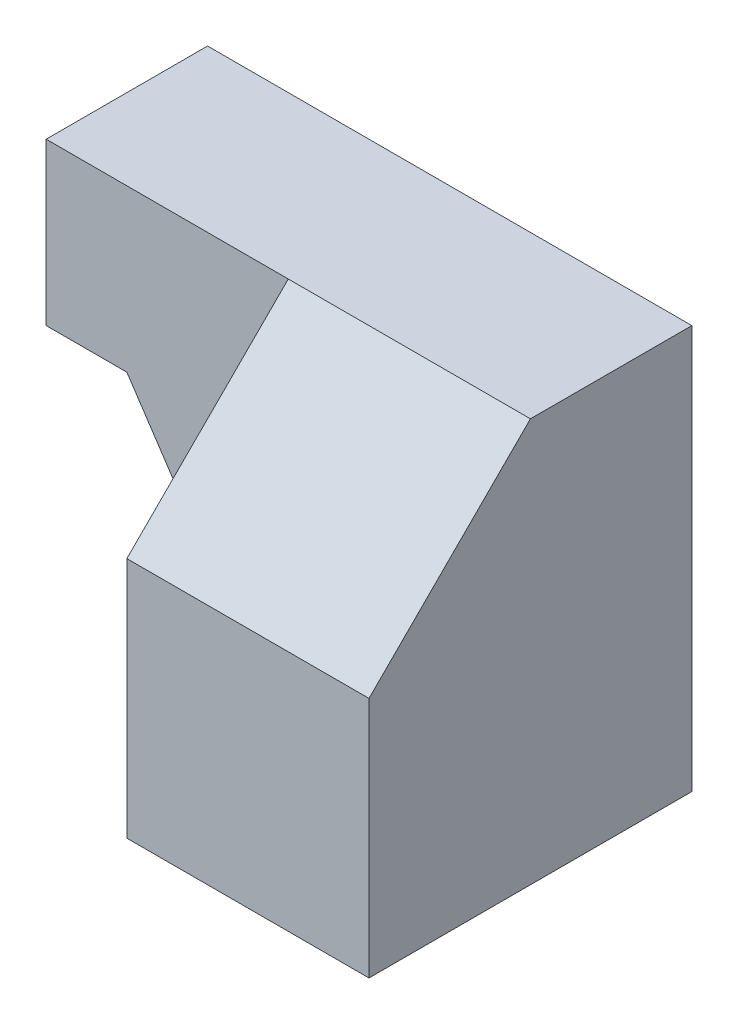
from build123d import *

# Parameters (mm, degrees)
BOSS_EXTRUDE1_DEPTH = 20
CUT_EXTRUDE1_DEPTH  = 10
CUT_EXTRUDE3_DEPTH  = 20


with BuildPart() as part:
    # Sketch1 → Boss-Extrude1 (new body)
    with BuildSketch(Plane.XY):
        Polygon((0, 0), (15, 0), (15, 25), (-15, 25), (-15, 15), (-10, 15), align=None)
    extrude(amount=BOSS_EXTRUDE1_DEPTH)

    # Sketch2 → Cut-Extrude1 (cut)
    with BuildSketch(Plane.XY.offset(20)):
        Polygon((0, 0), (0, 25), (-15, 25), (-15, 15), (-10, 15), align=None)
    extrude(amount=-CUT_EXTRUDE1_DEPTH, mode=Mode.SUBTRACT)

    # Sketch3 → Cut-Extrude3 (cut)
    with BuildSketch(Plane.ZY):
        Polygon((10, 25), (20, 15), (20, 25), align=None)
    extrude(amount=-CUT_EXTRUDE3_DEPTH, mode=Mode.SUBTRACT)


solid = part.part
